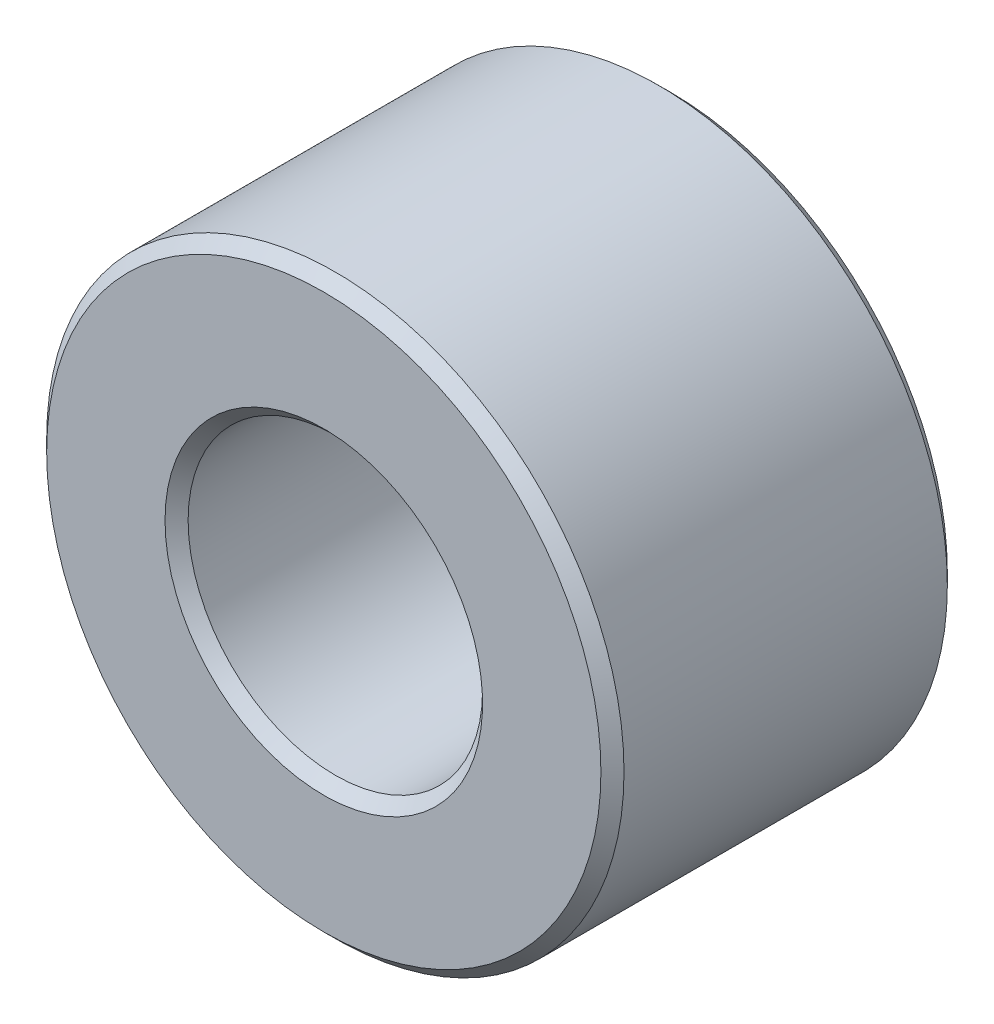
from build123d import *


with BuildPart() as part:
    # Sketch1 → Revolve1 (revolve)
    with BuildSketch(Plane.XZ):
        Polygon((2.75, 6), (2.55, 5.8), (2.55, 0.2), (2.75, 0), (4.8, 0), (5, 0.2), (5, 5.8), (4.8, 6), align=None)
    revolve(axis=Axis((0, 0, 6), (0, 0, -1)))


solid = part.part
